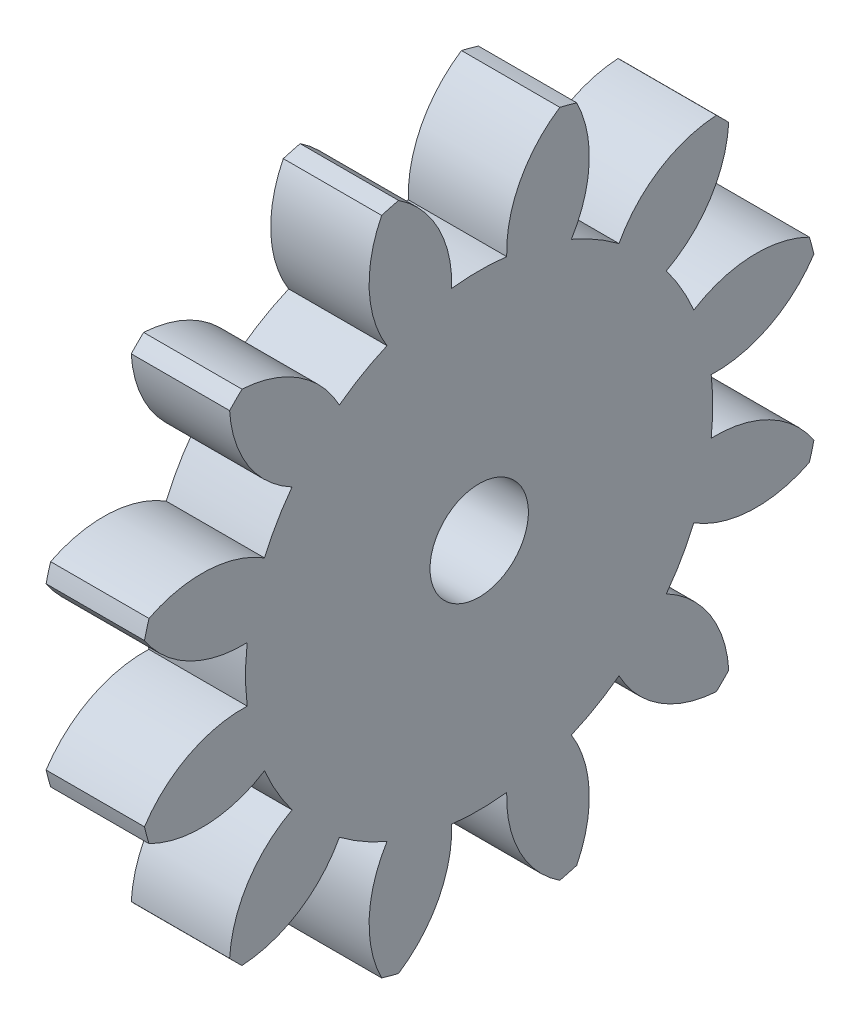
from build123d import *

# Parameters (mm, degrees)
BASPROSKE_W     = 12.7
BASPROSKE_H     = 44.45
TOOTHCUT_DEPTH  = 65.131856359
TEETHCUTS_COUNT = 12
TEETHCUTS_ANGLE = 330
BORSKE_R        = 6.35
BORE_DEPTH      = 50.8000508


with BuildPart() as part:
    # BasProSke → Base-Revolve (revolve)
    with BuildSketch(Plane(origin=(0, 0, 0), x_dir=(1, 0, 0), z_dir=(0, 1, 0)), mode=Mode.PRIVATE) as base_revolve_sk:
        with Locations((6.35, 22.225)):
            Rectangle(BASPROSKE_W, BASPROSKE_H)
    revolve(base_revolve_sk.sketch.rotate(Axis((-10, 0, 0), (1, 0, 0)), 180), axis=Axis((-10, 0, 0), (1, 0, 0)))

    # TooCutSke → ToothCut (cut, through all)
    with BuildSketch(Plane(origin=(0, 0, 0), x_dir=(0, 0, -1), z_dir=(1, 0, 0))):
        with BuildLine():
            ThreePointArc((3.552242783, 29.951316604), (0, 30.16123), (-3.552242783, 29.951316604))
            ThreePointArc((-3.552242783, 29.951316604), (-5.254049238, 37.49538421), (-10.439744342, 43.232776261))
            ThreePointArc((-10.439744342, 43.232776261), (0, 44.4754), (10.439744342, 43.232776261))
            ThreePointArc((10.439744342, 43.232776261), (5.254049238, 37.49538421), (3.552242783, 29.951316604))
        make_face()
    toothcut = extrude(amount=TOOTHCUT_DEPTH, mode=Mode.SUBTRACT)

    # TeethCuts: ToothCut ×12 about axis
    teethcuts_axis = Axis((-10, 0, 0), (1, 0, 0))
    for i in range(1, TEETHCUTS_COUNT):
        add(toothcut.rotate(teethcuts_axis, i * TEETHCUTS_ANGLE / (TEETHCUTS_COUNT - 1)), mode=Mode.SUBTRACT)

    # BorSke → Bore (cut, symmetric)
    with BuildSketch(Plane(origin=(0, 0, 0), x_dir=(0, 0, -1), z_dir=(1, 0, 0))):
        with Locations(Location((0, 0, 0), (0, 0, 180))):
            Circle(BORSKE_R)
    extrude(amount=BORE_DEPTH, both=True, mode=Mode.SUBTRACT)


solid = part.part
